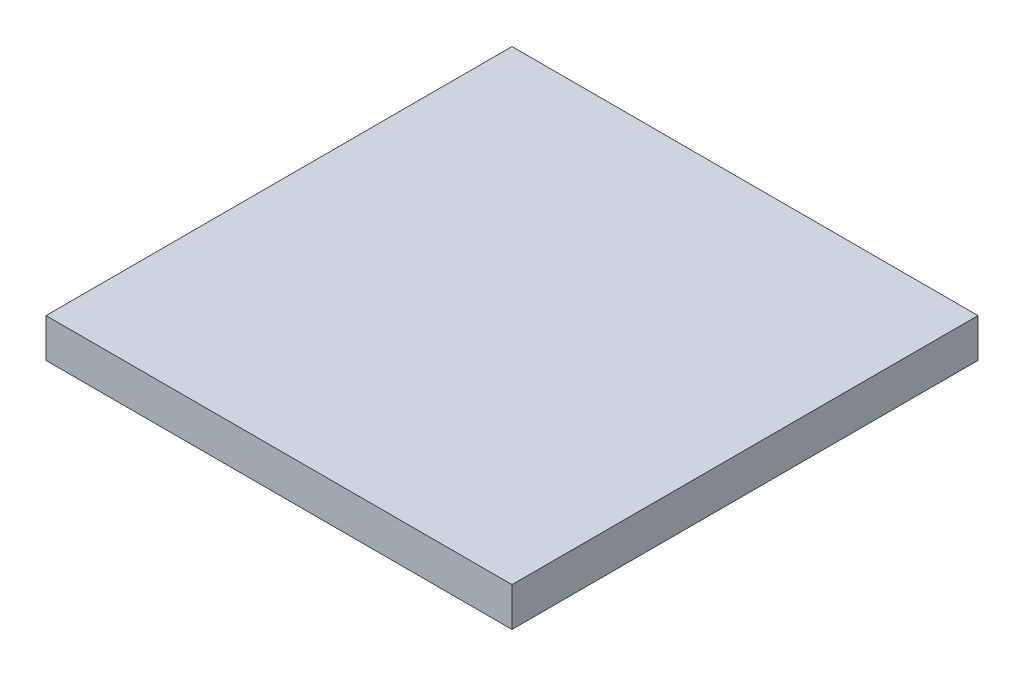
from build123d import *

# Parameters (mm, degrees)
SKETCH2_W           = 2400
SKETCH2_H           = 2400
BOSS_EXTRUDE1_DEPTH = 200


with BuildPart() as part:
    # Sketch2 → Boss-Extrude1 (new body)
    with BuildSketch(Plane(origin=(0, 0, 0), x_dir=(1, 0, 0), z_dir=(0, 1, 0))):
        with Locations((1200, 1200)):
            Rectangle(SKETCH2_W, SKETCH2_H)
    extrude(amount=BOSS_EXTRUDE1_DEPTH)


solid = part.part
